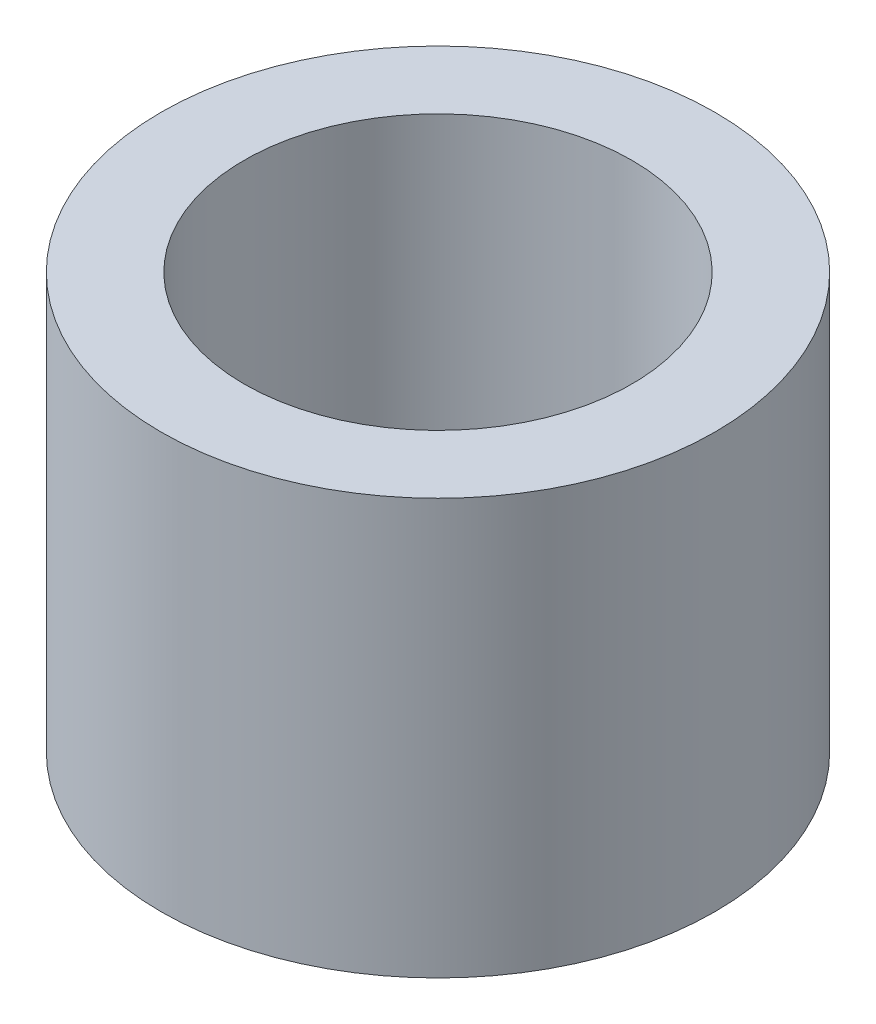
from build123d import *

# Parameters (mm, degrees)
SKETCH1_R           = 5
SKETCH1_R_2         = 3.5
BOSS_EXTRUDE1_DEPTH = 7.5


with BuildPart() as part:
    # Sketch1 → Boss-Extrude1 (new body)
    with BuildSketch(Plane(origin=(0, 0, 0), x_dir=(1, 0, 0), z_dir=(0, 1, 0))):
        Circle(SKETCH1_R)
        Circle(SKETCH1_R_2, mode=Mode.SUBTRACT)
    extrude(amount=BOSS_EXTRUDE1_DEPTH)


solid = part.part
